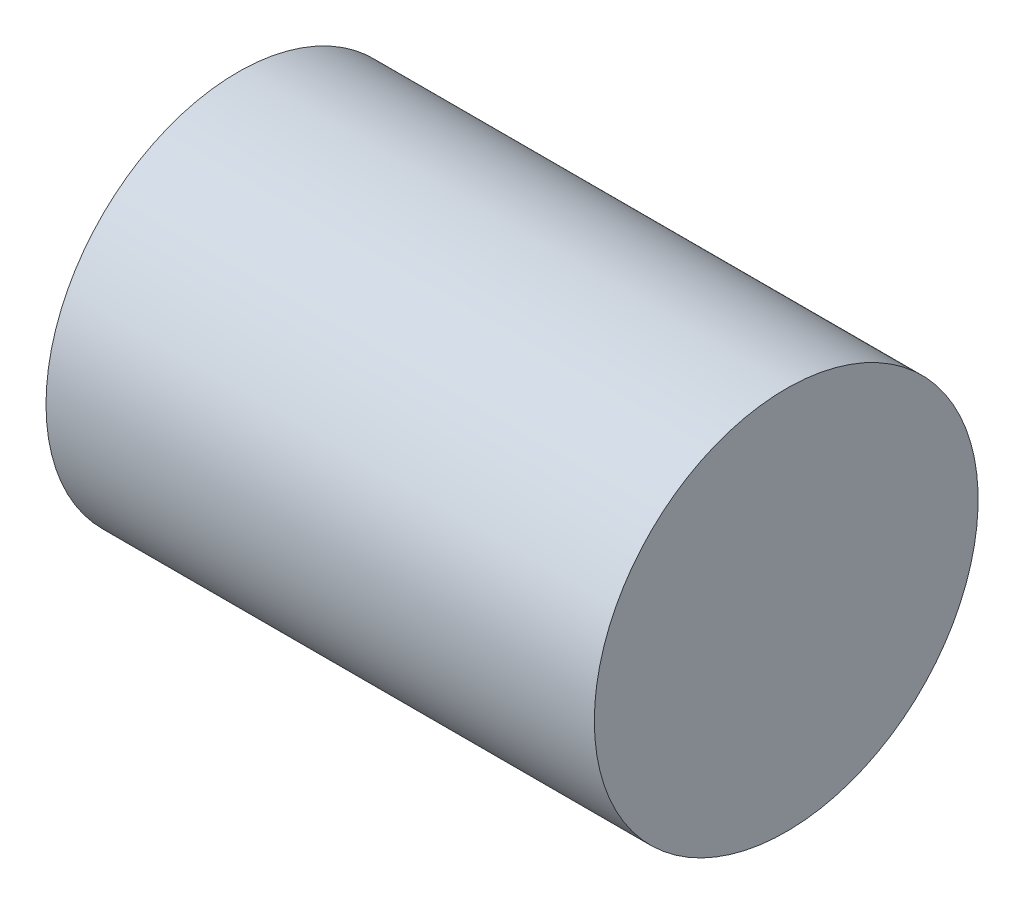
from build123d import *

# Parameters (mm, degrees)
SCHIZZO1_W = 40
SCHIZZO1_H = 14


with BuildPart() as part:
    # Schizzo1 → Rivoluzione1 (revolve)
    with BuildSketch(Plane.XY):
        with Locations((20, 7)):
            Rectangle(SCHIZZO1_W, SCHIZZO1_H)
    revolve(axis=Axis((0, 14, 0), (1, 0, 0)))


solid = part.part
